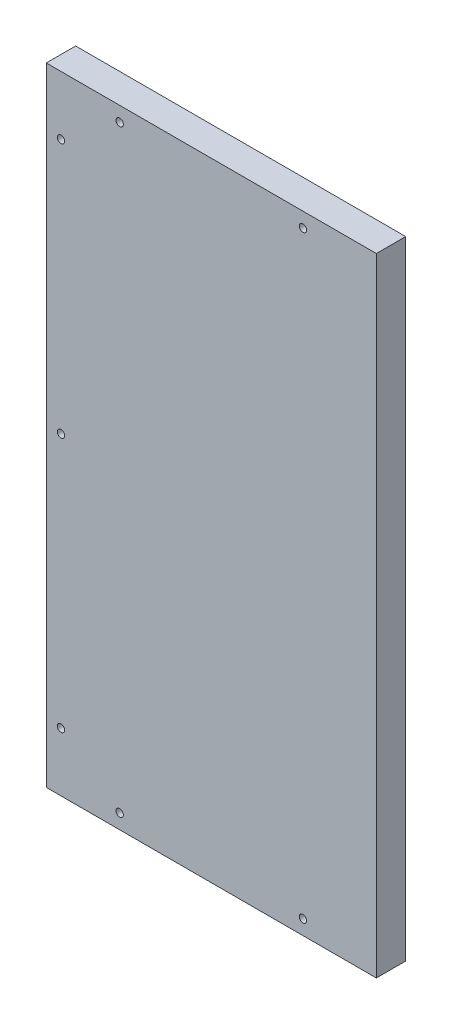
from build123d import *

# Parameters (mm, degrees)
SKETCH1_W           = 142.755639788
SKETCH1_H           = 271.365530146
BOSS_EXTRUDE1_DEPTH = 12.7
HOLE1_D             = 3.175
HOLE1_DEPTH         = 31.75
HOLE1_CSINK_D       = 10.16
HOLE1_CSINK_ANGLE   = 82
HOLE1_TIP           = 0.953866233


with BuildPart() as part:
    # Sketch1 → Boss-Extrude1 (new body)
    with BuildSketch(Plane.XY):
        with Locations((-163.375147287, -52.841023691)):
            Rectangle(SKETCH1_W, SKETCH1_H)
    extrude(amount=BOSS_EXTRUDE1_DEPTH)

    # Hole1
    with Locations(Plane(origin=(181.039434513, -52.974999997, 0), x_dir=(0, -1, 0), z_dir=(0, 0, -1))):
        with Locations((129.198788767, 384.042401694), (-129.466741379, 384.042401694), (-129.466741379, 304.786761906), (-110.416741379, 409.442401694), (-0.133976306, 409.442401694), (110.148788767, 409.442401694), (129.198788767, 304.786761906)):
            CounterSinkHole(HOLE1_D / 2, HOLE1_CSINK_D / 2, depth=HOLE1_DEPTH, counter_sink_angle=HOLE1_CSINK_ANGLE)
            with Locations((0, 0, -(HOLE1_DEPTH + HOLE1_TIP / 2))):  # 118° drill point
                Cone(0, HOLE1_D / 2, HOLE1_TIP, mode=Mode.SUBTRACT)


solid = part.part
